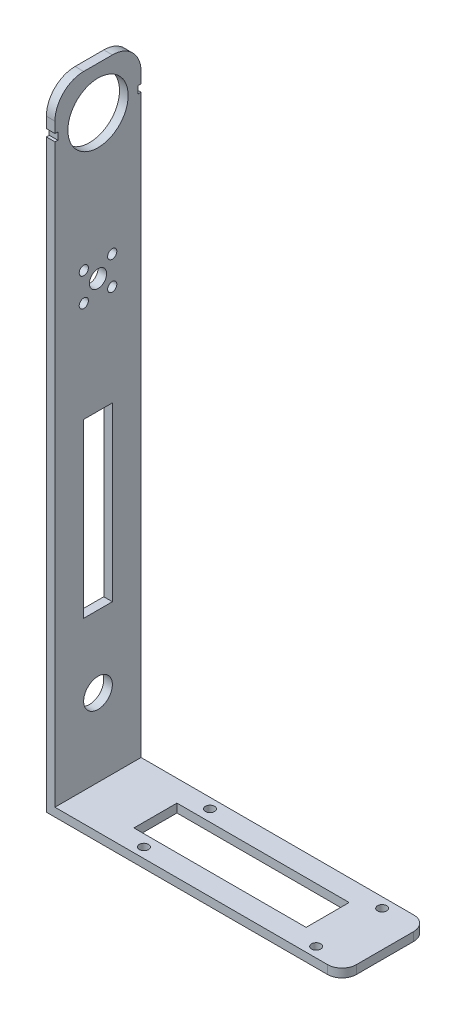
from build123d import *

# Parameters (mm, degrees)
SKETCH_1_W          = 30
SKETCH_1_H          = 170
EXTRUDE_1_DEPTH     = 3
SKETCH_2_W          = 30
SKETCH_2_H          = 3
EXTRUDE_2_DEPTH     = 100
SKETCH_4_R          = 1.6
SKETCH_4_R_2        = 3
CUT_EXTRUDE_1_DEPTH = 104
SKETCH_5_W          = 3
SKETCH_5_H          = 30
EXTRUDE_3_DEPTH     = 50
SKETCH_6_R          = 10.5
SKETCH_6_W          = 2
SKETCH_6_H          = 2.5
CUT_EXTRUDE_2_DEPTH = 104
FILLET_1_R          = 10
SKETCH_7_R          = 1.6
SKETCH_7_W          = 60
SKETCH_7_H          = 15
CUT_EXTRUDE_3_DEPTH = 4
FILLET_2_R          = 5
SKETCH_8_R          = 5
SKETCH_8_W          = 10
SKETCH_8_H          = 60
CUT_EXTRUDE_4_DEPTH = 104


with BuildPart() as part:
    # 草图1 → 凸台-拉伸1 (new body)
    with BuildSketch(Plane(origin=(0, 0, 0), x_dir=(0, 0, -1), z_dir=(1, 0, 0))):
        Rectangle(SKETCH_1_W, SKETCH_1_H)
    extrude(amount=EXTRUDE_1_DEPTH)

    # 草图2 → 凸台-拉伸2 (add)
    with BuildSketch(Plane(origin=(3, 0, 0), x_dir=(0, 0, -1), z_dir=(1, 0, 0))):
        with Locations((0, -83.5)):
            Rectangle(SKETCH_2_W, SKETCH_2_H)
    extrude(amount=EXTRUDE_2_DEPTH)

    # 草图4 → 切除-拉伸1 (cut, through all)
    with BuildSketch(Plane.ZY):
        with Locations((-4.949747468, 74.949747468)):
            Circle(SKETCH_4_R)
        with Locations((4.949747468, 74.949747468)):
            Circle(SKETCH_4_R)
        with Locations((4.949747468, 65.050252532)):
            Circle(SKETCH_4_R)
        with Locations((-4.949747468, 65.050252532)):
            Circle(SKETCH_4_R)
        with Locations((0, 70)):
            Circle(SKETCH_4_R_2)
    extrude(amount=-CUT_EXTRUDE_1_DEPTH, mode=Mode.SUBTRACT)

    # 草图5 → 凸台-拉伸3 (add)
    with BuildSketch(Plane(origin=(0, 85, 0), x_dir=(1, 0, 0), z_dir=(0, 1, 0))):
        with Locations((1.5, 0)):
            Rectangle(SKETCH_5_W, SKETCH_5_H)
    extrude(amount=EXTRUDE_3_DEPTH)

    # 草图6 → 切除-拉伸2 (cut, through all)
    with BuildSketch(Plane.ZY):
        with Locations((0, 120)):
            Circle(SKETCH_6_R)
        with Locations((-15, 120)):
            Rectangle(SKETCH_6_W, SKETCH_6_H)
        with Locations((15, 120)):
            Rectangle(SKETCH_6_W, SKETCH_6_H)
    extrude(amount=-CUT_EXTRUDE_2_DEPTH, mode=Mode.SUBTRACT)

    # 圆角1
    fillet_1_edges = [part.edges().sort_by_distance(p)[0] for p in [
        (1.5, 135, 15),
        (1.5, 135, -15),
    ]]
    fillet(fillet_1_edges, radius=FILLET_1_R)

    # 草图7 → 切除-拉伸3 (cut, through all)
    with BuildSketch(Plane(origin=(0, -82, 0), x_dir=(1, 0, 0), z_dir=(0, 1, 0))):
        with Locations((90.5, 11.5)):
            Circle(SKETCH_7_R)
        with Locations((30.5, 11.5)):
            Circle(SKETCH_7_R)
        with Locations((90.5, -11.5)):
            Circle(SKETCH_7_R)
        with Locations((30.5, -11.5)):
            Circle(SKETCH_7_R)
        with Locations((53, 0)):
            Rectangle(SKETCH_7_W, SKETCH_7_H)
    extrude(amount=-CUT_EXTRUDE_3_DEPTH, mode=Mode.SUBTRACT)

    # 圆角2
    fillet_2_edges = [part.edges().sort_by_distance(p)[0] for p in [
        (103, -83.5, 15),
        (103, -83.5, -15),
    ]]
    fillet(fillet_2_edges, radius=FILLET_2_R)

    # 草图8 → 切除-拉伸4 (cut, through all)
    with BuildSketch(Plane.ZY):
        with Locations((0, -55)):
            Circle(SKETCH_8_R)
        Rectangle(SKETCH_8_W, SKETCH_8_H)
    extrude(amount=-CUT_EXTRUDE_4_DEPTH, mode=Mode.SUBTRACT)


solid = part.part
